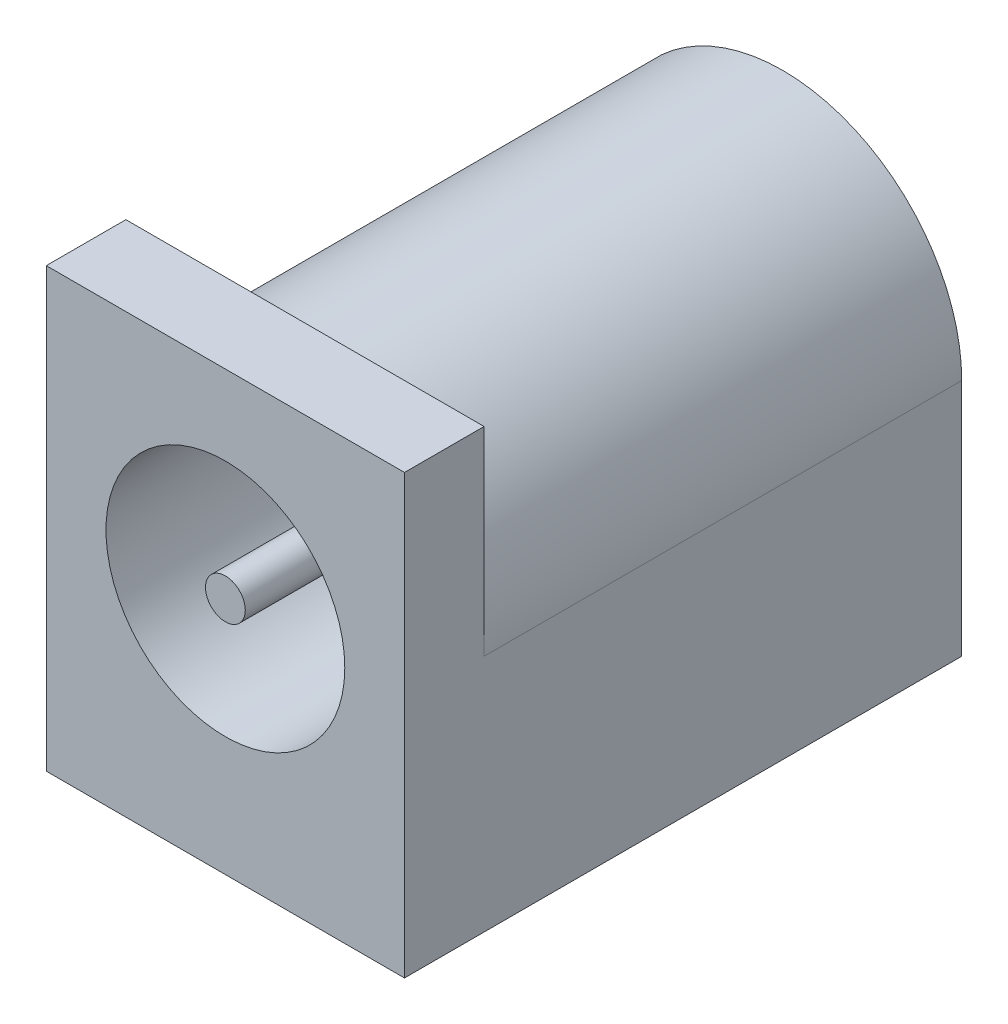
from build123d import *

# Parameters (mm, degrees)
SKETCH1_W           = 9
SKETCH1_H           = 11
BOSS_EXTRUDE1_DEPTH = 14
SKETCH2_R           = 3
CUT_EXTRUDE1_DEPTH  = 12
SKETCH3_OUTSIDE_W   = 14.99
SKETCH3_OUTSIDE_H   = 16.99
CUT_EXTRUDE2_DEPTH  = 12
SKETCH4_R           = 1
BOSS_EXTRUDE2_DEPTH = 2
SKETCH5_R           = 0.5
BOSS_EXTRUDE3_DEPTH = 10


with BuildPart() as part:
    # Sketch1 → Boss-Extrude1 (new body)
    with BuildSketch(Plane.XY):
        Rectangle(SKETCH1_W, SKETCH1_H)
    extrude(amount=BOSS_EXTRUDE1_DEPTH)

    # Sketch2 → Cut-Extrude1 (cut)
    with BuildSketch(Plane.XY.offset(14)):
        with Locations((0, 0.5)):
            Circle(SKETCH2_R)
    extrude(amount=-CUT_EXTRUDE1_DEPTH, mode=Mode.SUBTRACT)

    # Sketch3 outside → Cut-Extrude2 (cut)
    with BuildSketch(Plane(origin=(0, 0, 0), x_dir=(-1, 0, 0), z_dir=(0, 0, -1))):
        Rectangle(SKETCH3_OUTSIDE_W, SKETCH3_OUTSIDE_H)
        with BuildLine():
            Line((-4.5, 0.5), (-4.5, -5.5))
            Line((-4.5, -5.5), (4.5, -5.5))
            Line((4.5, -5.5), (4.5, 0.5))
            ThreePointArc((4.5, 0.5), (0, 5), (-4.5, 0.5))
        make_face(mode=Mode.SUBTRACT)
    extrude(amount=-CUT_EXTRUDE2_DEPTH, mode=Mode.SUBTRACT)

    # Sketch4 → Boss-Extrude2 (add)
    with BuildSketch(Plane.XY.offset(2)):
        with Locations((0, 0.5)):
            Circle(SKETCH4_R)
    extrude(amount=BOSS_EXTRUDE2_DEPTH)

    # Sketch5 → Boss-Extrude3 (add)
    with BuildSketch(Plane.XY.offset(4)):
        with Locations((0, 0.5)):
            Circle(SKETCH5_R)
    extrude(amount=BOSS_EXTRUDE3_DEPTH)


solid = part.part
